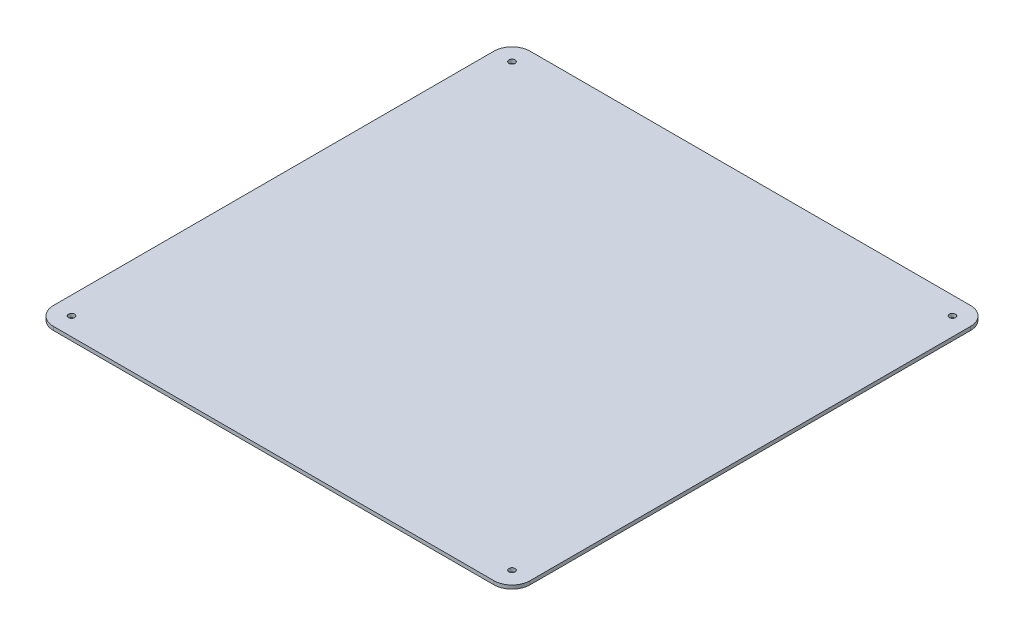
from build123d import *

# Parameters (mm, degrees)
SKETCH1_W           = 395
SKETCH1_H           = 395
SKETCH1_R           = 2.55
BOSS_EXTRUDE1_DEPTH = 3
FILLET1_R           = 15


with BuildPart() as part:
    # Sketch1 → Boss-Extrude1 (new body)
    with BuildSketch(Plane(origin=(0, 0, 0), x_dir=(1, 0, 0), z_dir=(0, 1, 0))):
        Rectangle(SKETCH1_W, SKETCH1_H)
        with Locations((-182.5, 182.5)):
            Circle(SKETCH1_R, mode=Mode.SUBTRACT)
        with Locations((182.5, 182.5)):
            Circle(SKETCH1_R, mode=Mode.SUBTRACT)
        with Locations((182.5, -182.5)):
            Circle(SKETCH1_R, mode=Mode.SUBTRACT)
        with Locations((-182.5, -182.5)):
            Circle(SKETCH1_R, mode=Mode.SUBTRACT)
    extrude(amount=BOSS_EXTRUDE1_DEPTH)

    # Fillet1
    fillet1_edges = [part.edges().sort_by_distance(p)[0] for p in [
        (197.5, 1.5, 197.5),
        (-197.5, 1.5, 197.5),
        (-197.5, 1.5, -197.5),
        (197.5, 1.5, -197.5),
    ]]
    fillet(fillet1_edges, radius=FILLET1_R)


solid = part.part
